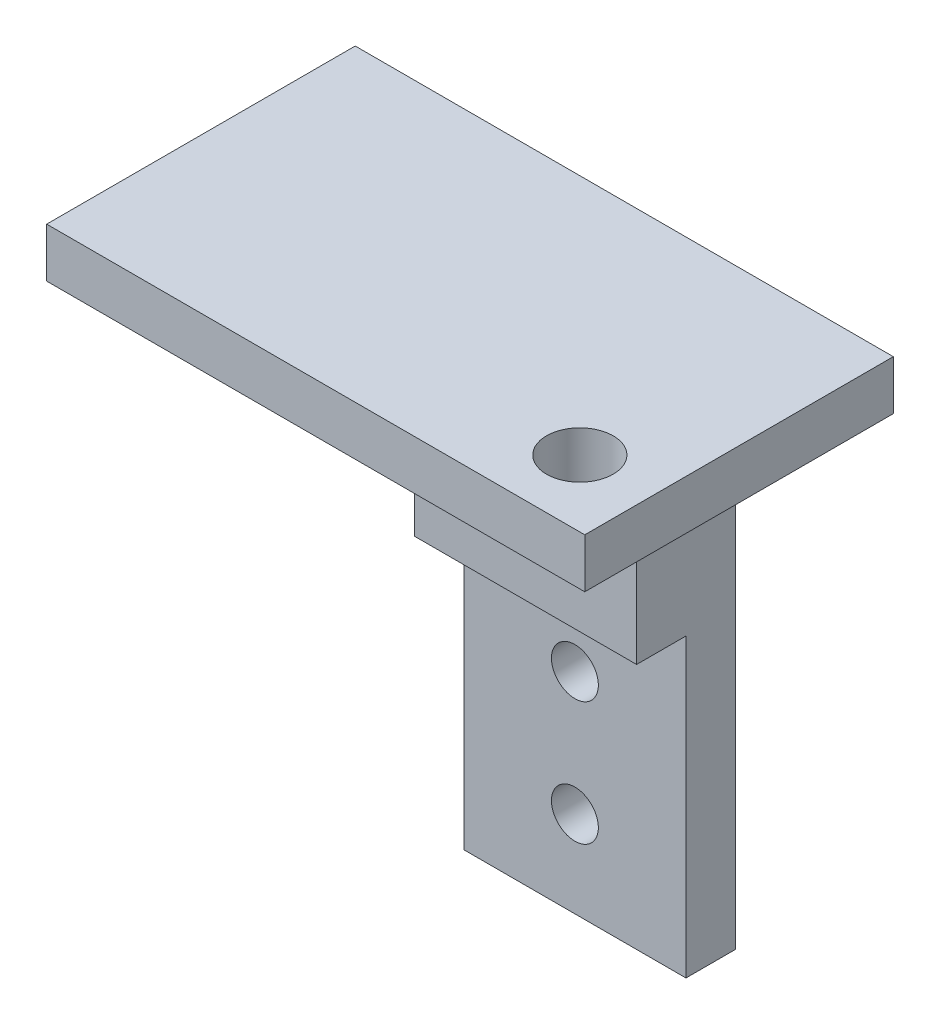
from build123d import *

# Parameters (mm, degrees)
SKETCH1_W           = 21.8
SKETCH1_H           = 12.5
BOSS_EXTRUDE1_DEPTH = 2
CUT_EXTRUDE1_REACH  = 4
SKETCH2_R           = 1.8
SKETCH3_W           = 9
SKETCH3_H           = 2
BOSS_EXTRUDE2_DEPTH = 22
SKETCH4_R           = 0.95
CUT_EXTRUDE2_DEPTH  = 13.5
SKETCH5_R           = 1.8
SKETCH5_R_2         = 1.35
BOSS_EXTRUDE3_DEPTH = 2
SKETCH6_W           = 9
SKETCH6_H           = 2
BOSS_EXTRUDE4_DEPTH = 10


with BuildPart() as part:
    # Sketch1 → Boss-Extrude1 (new body)
    with BuildSketch(Plane(origin=(0, 0, 0), x_dir=(1, 0, 0), z_dir=(0, 1, 0))):
        Rectangle(SKETCH1_W, SKETCH1_H)
    extrude(amount=BOSS_EXTRUDE1_DEPTH)

    # Sketch2 → Cut-Extrude1 (cut, up to next)
    with BuildSketch(Plane(origin=(0, 2, 0), x_dir=(1, 0, 0), z_dir=(0, 1, 0)), mode=Mode.PRIVATE) as cut_extrude1_sk1:
        with Locations((8, -3.55)):
            Circle(SKETCH2_R)
    cut_extrude1_tool1 = extrude(cut_extrude1_sk1.sketch, amount=-CUT_EXTRUDE1_REACH, mode=Mode.PRIVATE) & part.part
    add(cut_extrude1_tool1.solids().sort_by_distance((8, 2, 3.55))[0], mode=Mode.SUBTRACT)

    # Sketch3 → Boss-Extrude2 (add)
    with BuildSketch(Plane.XZ):
        with Locations((0, -5.25)):
            Rectangle(SKETCH3_W, SKETCH3_H)
    extrude(amount=BOSS_EXTRUDE2_DEPTH)

    # Sketch4 → Cut-Extrude2 (cut, through all)
    with BuildSketch(Plane(origin=(0, 0, -6.25), x_dir=(-1, 0, 0), z_dir=(0, 0, -1))):
        with Locations((0, -13.5)):
            Circle(SKETCH4_R)
        with Locations((0, -18.5)):
            Circle(SKETCH4_R)
    extrude(amount=-CUT_EXTRUDE2_DEPTH, mode=Mode.SUBTRACT)

    # Sketch5 → Boss-Extrude3 (add)
    with BuildSketch(Plane(origin=(0, 2, 0), x_dir=(1, 0, 0), z_dir=(0, 1, 0))):
        with Locations((8, -3.55)):
            Circle(SKETCH5_R)
        with Locations((8, -3.55)):
            Circle(SKETCH5_R_2, mode=Mode.SUBTRACT)
    extrude(amount=-BOSS_EXTRUDE3_DEPTH)

    # Sketch6 → Boss-Extrude4 (add)
    with BuildSketch(Plane.XZ):
        with Locations((0, -3.25)):
            Rectangle(SKETCH6_W, SKETCH6_H)
    extrude(amount=BOSS_EXTRUDE4_DEPTH)


solid = part.part
